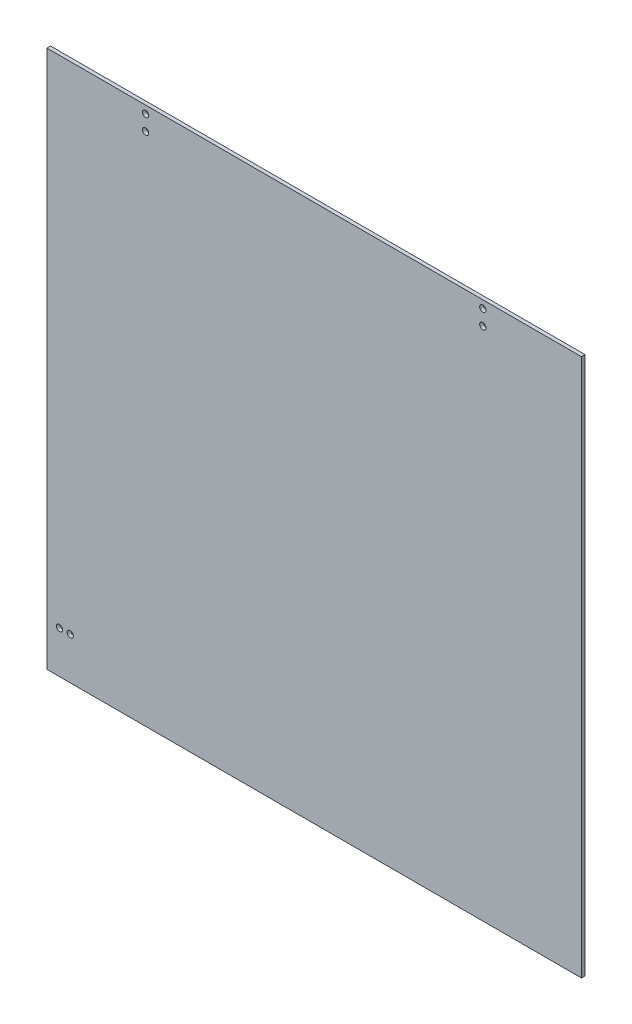
from build123d import *

# Parameters (mm, degrees)
SKETCH1_W               = 298
SKETCH1_H               = 300
BOSS_EXTRUDE1_DEPTH     = 2
SKETCH2_R               = 1.75
CUT_EXTRUDE1_DEPTH      = 20
SKETCH3_R               = 1.75
CUT_EXTRUDE2_DEPTH      = 1
CUT_EXTRUDE2_DEPTH_BACK = 3
SKETCH5_R               = 1.75
CUT_EXTRUDE3_DEPTH      = 3


with BuildPart() as part:
    # Sketch1 → Boss-Extrude1 (new body)
    with BuildSketch(Plane.XY):
        with Locations((149, 150)):
            Rectangle(SKETCH1_W, SKETCH1_H)
    extrude(amount=BOSS_EXTRUDE1_DEPTH)

    # Sketch2 → Cut-Extrude1 (cut)
    with BuildSketch(Plane.XY.offset(2)):
        with Locations((243, 295.75)):
            Circle(SKETCH2_R)
        with Locations((243, 287.25)):
            Circle(SKETCH2_R)
    extrude(amount=-CUT_EXTRUDE1_DEPTH, mode=Mode.SUBTRACT)

    # Sketch3 → Cut-Extrude2 (cut, two sides)
    with BuildSketch(Plane.XY.offset(2)) as cut_extrude2_sk:
        with Locations((55, 287.25)):
            Circle(SKETCH3_R)
        with Locations((55, 295.75)):
            Circle(SKETCH3_R)
    extrude(amount=CUT_EXTRUDE2_DEPTH, mode=Mode.SUBTRACT)
    extrude(cut_extrude2_sk.sketch, amount=-CUT_EXTRUDE2_DEPTH_BACK, mode=Mode.SUBTRACT)

    # Sketch5 → Cut-Extrude3 (cut, through all)
    with BuildSketch(Plane.XY.offset(2)):
        with Locations((7, 23.5)):
            Circle(SKETCH5_R)
        with Locations((13, 23.5)):
            Circle(SKETCH5_R)
    extrude(amount=-CUT_EXTRUDE3_DEPTH, mode=Mode.SUBTRACT)


solid = part.part
